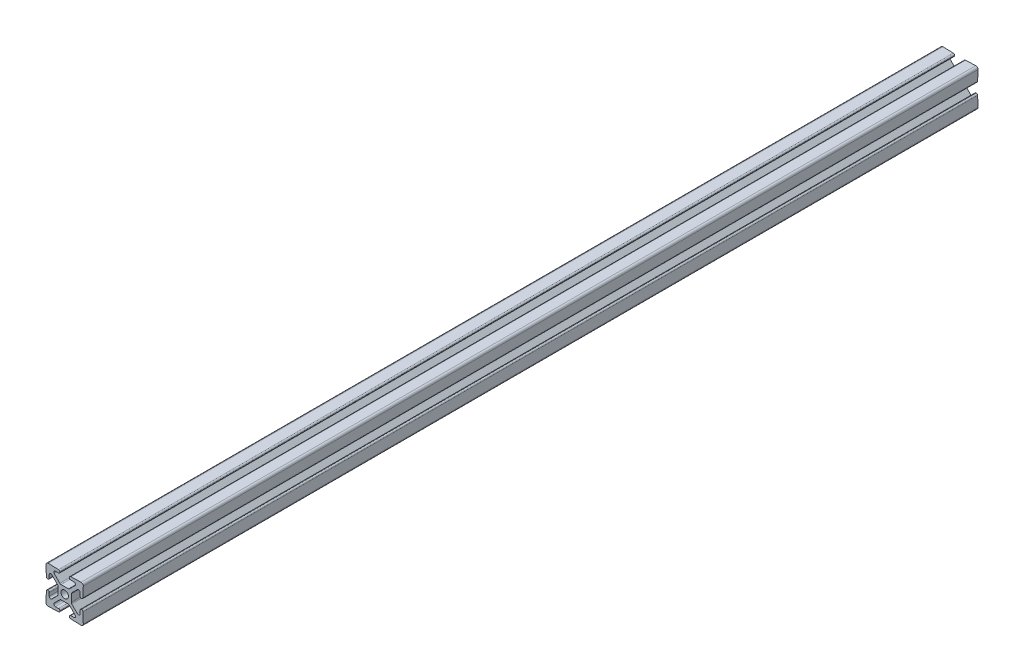
from build123d import *

# Parameters (mm, degrees)
SKETCH1_R      = 2.5527
EXTRUDE1_DEPTH = 304.8


with BuildPart() as part:
    # Sketch1 → Extrude1 (new body, symmetric)
    with BuildSketch(Plane.XY):
        with BuildLine():
            Line((3.238504286, -11.455400345), (3.238504286, -11.49073383))
            ThreePointArc((3.238504286, -11.49073383), (3.509397472, -12.161218003), (4.170019162, -12.455345741))
            Line((4.170019162, -12.455345741), (11.176001705, -12.7))
            ThreePointArc((11.176001705, -12.7), (12.253632411, -12.253630746), (12.700001664, -11.17600004))
            Line((12.700001664, -11.17600004), (12.455347406, -4.170014669))
            ThreePointArc((12.455347406, -4.170014669), (12.16121968, -3.509392954), (11.490735494, -3.238499755))
            Line((11.490735494, -3.238499755), (11.455402009, -3.238499755))
            ThreePointArc((11.455402009, -3.238499755), (10.772902626, -3.521200256), (10.490202125, -4.20369964))
            Line((10.490202125, -4.20369964), (10.490202125, -6.352134987))
            ThreePointArc((10.490202125, -6.352134987), (9.831646779, -7.337732713), (8.669054992, -7.106478829))
            Line((8.669054992, -7.106478829), (4.820959759, -3.258383596))
            ThreePointArc((4.820959759, -3.258383596), (4.589705874, -2.912287699), (4.508500309, -2.504039754))
            Line((4.508500309, -2.504039754), (4.508500309, 2.504040946))
            ThreePointArc((4.508500309, 2.504040946), (4.589705874, 2.912288891), (4.820959759, 3.258384788))
            Line((4.820959759, 3.258384788), (8.669054992, 7.106480021))
            ThreePointArc((8.669054992, 7.106480021), (9.831646779, 7.337733906), (10.490202125, 6.35213618))
            Line((10.490202125, 6.35213618), (10.490202125, 4.203700832))
            ThreePointArc((10.490202125, 4.203700832), (10.772902626, 3.521201448), (11.455402009, 3.238500947))
            Line((11.455402009, 3.238500947), (11.490735494, 3.238500947))
            ThreePointArc((11.490735494, 3.238500947), (12.161219667, 3.509394133), (12.455347406, 4.170015823))
            Line((12.455347406, 4.170015823), (12.700001664, 11.176000039))
            ThreePointArc((12.700001664, 11.176000039), (12.253632411, 12.253630745), (11.176001705, 12.699999999))
            Line((11.176001705, 12.699999999), (4.170019162, 12.455345462))
            ThreePointArc((4.170019162, 12.455345462), (3.509397447, 12.161217736), (3.238504248, 11.49073355))
            Line((3.238504248, 11.49073355), (3.238504248, 11.455400065))
            ThreePointArc((3.238504248, 11.455400065), (3.521204749, 10.772900682), (4.203704132, 10.490200181))
            Line((4.203704132, 10.490200181), (6.35213948, 10.490200181))
            ThreePointArc((6.35213948, 10.490200181), (7.337737205, 9.831644835), (7.106483322, 8.669053049))
            Line((7.106483322, 8.669053049), (3.258388088, 4.820957816))
            ThreePointArc((3.258388088, 4.820957816), (2.912292192, 4.589703931), (2.504044247, 4.508498366))
            Line((2.504044247, 4.508498366), (-2.504036453, 4.508498366))
            ThreePointArc((-2.504036453, 4.508498366), (-2.912284398, 4.589703931), (-3.258380295, 4.820957816))
            Line((-3.258380295, 4.820957816), (-7.106475528, 8.669053049))
            ThreePointArc((-7.106475528, 8.669053049), (-7.337729412, 9.831644836), (-6.352131686, 10.490200182))
            Line((-6.352131686, 10.490200182), (-4.203696339, 10.490200182))
            ThreePointArc((-4.203696339, 10.490200182), (-3.521196955, 10.772900683), (-3.238496454, 11.455400067))
            Line((-3.238496454, 11.455400067), (-3.238496454, 11.490733551))
            ThreePointArc((-3.238496454, 11.490733551), (-3.50938964, 12.161217724), (-4.17001133, 12.455345462))
            Line((-4.17001133, 12.455345462), (-11.175998375, 12.699999999))
            ThreePointArc((-11.175998375, 12.699999999), (-12.253629081, 12.253630745), (-12.699998335, 11.176000039))
            Line((-12.699998335, 11.176000039), (-12.455343798, 4.170015823))
            ThreePointArc((-12.455343798, 4.170015823), (-12.161216073, 3.509394108), (-11.490731887, 3.238500909))
            Line((-11.490731887, 3.238500909), (-11.455398403, 3.238500909))
            ThreePointArc((-11.455398403, 3.238500909), (-10.772899019, 3.52120141), (-10.490198518, 4.203700793))
            Line((-10.490198518, 4.203700793), (-10.490198518, 6.352136141))
            ThreePointArc((-10.490198518, 6.352136141), (-9.831643172, 7.337733867), (-8.669051385, 7.106479983))
            Line((-8.669051385, 7.106479983), (-4.820956152, 3.258384749))
            ThreePointArc((-4.820956152, 3.258384749), (-4.589702267, 2.912288853), (-4.508496702, 2.504040908))
            Line((-4.508496702, 2.504040908), (-4.508496702, -2.504039793))
            ThreePointArc((-4.508496702, -2.504039793), (-4.589702267, -2.912287738), (-4.820956152, -3.258383634))
            Line((-4.820956152, -3.258383634), (-8.669051385, -7.106478867))
            ThreePointArc((-8.669051385, -7.106478867), (-9.831643172, -7.337732752), (-10.490198518, -6.352135026))
            Line((-10.490198518, -6.352135026), (-10.490198518, -4.203699678))
            ThreePointArc((-10.490198518, -4.203699678), (-10.772899019, -3.521200294), (-11.455398403, -3.238499793))
            Line((-11.455398403, -3.238499793), (-11.490731887, -3.238499793))
            ThreePointArc((-11.490731887, -3.238499793), (-12.16121606, -3.509392979), (-12.455343798, -4.170014669))
            Line((-12.455343798, -4.170014669), (-12.699998335, -11.17600004))
            ThreePointArc((-12.699998335, -11.17600004), (-12.253629081, -12.253630746), (-11.175998375, -12.7))
            Line((-11.175998375, -12.7), (-4.17001133, -12.455345741))
            ThreePointArc((-4.17001133, -12.455345741), (-3.509389615, -12.161218016), (-3.238496416, -11.49073383))
            Line((-3.238496416, -11.49073383), (-3.238496416, -11.455400345))
            ThreePointArc((-3.238496416, -11.455400345), (-3.521196917, -10.772900961), (-4.2036963, -10.49020046))
            Line((-4.2036963, -10.49020046), (-6.352131648, -10.49020046))
            ThreePointArc((-6.352131648, -10.49020046), (-7.337729374, -9.831645114), (-7.106475489, -8.669053328))
            Line((-7.106475489, -8.669053328), (-3.258380256, -4.820958094))
            ThreePointArc((-3.258380256, -4.820958094), (-2.91228436, -4.58970421), (-2.504036415, -4.508498645))
            Line((-2.504036415, -4.508498645), (2.504044285, -4.508498645))
            ThreePointArc((2.504044285, -4.508498645), (2.91229223, -4.58970421), (3.258388127, -4.820958094))
            Line((3.258388127, -4.820958094), (7.10648336, -8.669053328))
            ThreePointArc((7.10648336, -8.669053328), (7.337737245, -9.831645114), (6.352139519, -10.49020046))
            Line((6.352139519, -10.49020046), (4.203704171, -10.49020046))
            ThreePointArc((4.203704171, -10.49020046), (3.521204787, -10.772900961), (3.238504286, -11.455400345))
        make_face()
        Circle(SKETCH1_R, mode=Mode.SUBTRACT)
    extrude(amount=EXTRUDE1_DEPTH, both=True)


solid = part.part
